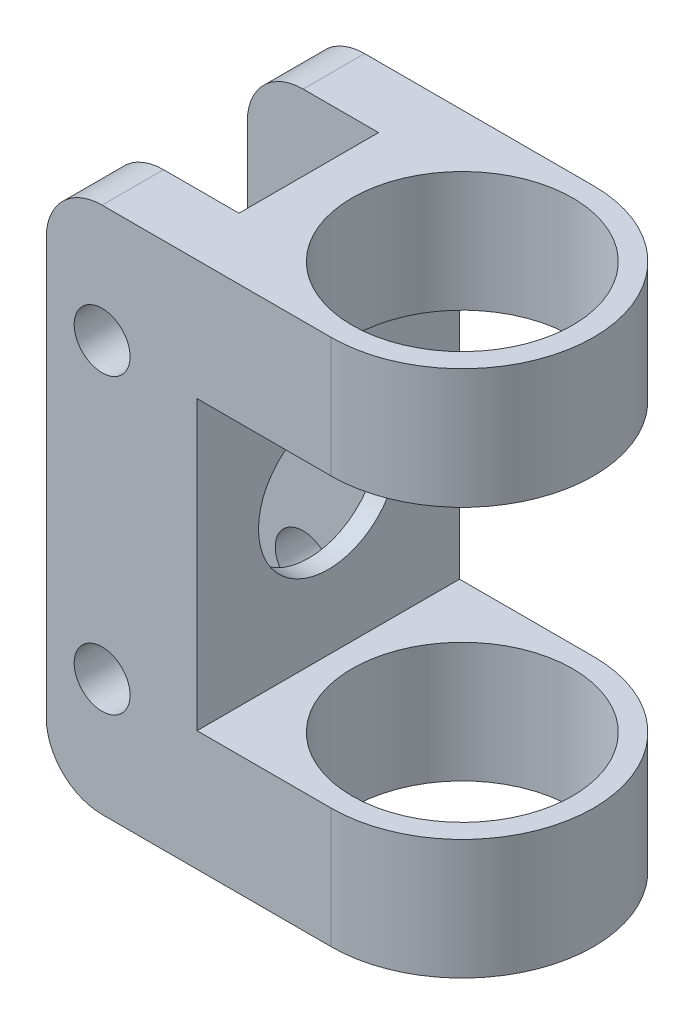
from build123d import *

# Parameters (mm, degrees)
SKETCH1_R               = 10.033
BOSS_EXTRUDE1_DEPTH     = 24.003
SKETCH3_R               = 2.54
SKETCH3_W               = 24.13
SKETCH3_H               = 26.162
CUT_EXTRUDE1_DEPTH      = 12.938
CUT_EXTRUDE1_DEPTH_BACK = 12.938
SKETCH5_R               = 6.35
CUT_EXTRUDE2_DEPTH      = 26.908
FILLET1_R               = 5.08


with BuildPart() as part:
    # Sketch1 → Boss-Extrude1 (new body, symmetric)
    with BuildSketch(Plane(origin=(0, 0, 0), x_dir=(1, 0, 0), z_dir=(0, 1, 0))):
        with BuildLine():
            Line((0, 11.938), (-25.908, 11.938))
            Line((-25.908, 11.938), (-25.908, 6.35))
            Line((-25.908, 6.35), (-13.97, 6.35))
            Line((-13.97, 6.35), (-13.97, -6.35))
            Line((-13.97, -6.35), (-25.908, -6.35))
            Line((-25.908, -6.35), (-25.908, -11.938))
            Line((-25.908, -11.938), (0, -11.938))
            ThreePointArc((0, -11.938), (11.938, 0), (0, 11.938))
        make_face()
        Circle(SKETCH1_R, mode=Mode.SUBTRACT)
    extrude(amount=BOSS_EXTRUDE1_DEPTH, both=True)

    # Sketch3 → Cut-Extrude1 (cut, two sides)
    with BuildSketch(Plane.XY) as cut_extrude1_sk:
        with Locations((-20.828, 13.335)):
            Circle(SKETCH3_R)
        with Locations((-20.828, -13.335)):
            Circle(SKETCH3_R)
        with Locations((-0.127, 0)):
            Rectangle(SKETCH3_W, SKETCH3_H)
    extrude(amount=CUT_EXTRUDE1_DEPTH, mode=Mode.SUBTRACT)
    extrude(cut_extrude1_sk.sketch, amount=-CUT_EXTRUDE1_DEPTH_BACK, mode=Mode.SUBTRACT)

    # Sketch5 → Cut-Extrude2 (cut, through all)
    with BuildSketch(Plane(origin=(0, 0, 0), x_dir=(0, 0, -1), z_dir=(1, 0, 0))):
        Circle(SKETCH5_R)
    extrude(amount=-CUT_EXTRUDE2_DEPTH, mode=Mode.SUBTRACT)

    # Fillet1
    fillet1_edges = [part.edges().sort_by_distance(p)[0] for p in [
        (-25.908, 24.003, -9.144),
        (-25.908, 24.003, 9.144),
        (-25.908, -24.003, 9.144),
        (-25.908, -24.003, -9.144),
    ]]
    fillet(fillet1_edges, radius=FILLET1_R)


solid = part.part
